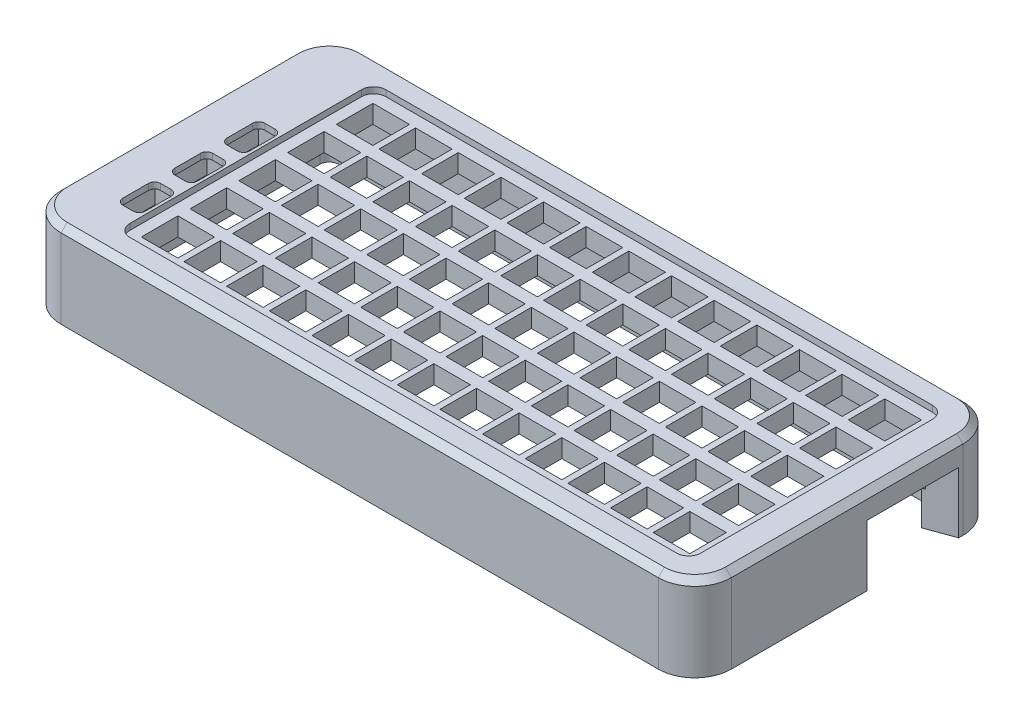
from build123d import *

# Parameters (mm, degrees)
SKETCH_1_W          = 110
SKETCH_1_H          = 50
EXTRUDE_1_DEPTH     = 3
SKETCH_2_W          = 6
SKETCH_2_H          = 6
CUT_EXTRUDE_1_DEPTH = 10
SKETCH_3_W          = 110
SKETCH_3_H          = 50
SKETCH_3_W_2        = 93.7
SKETCH_3_H_2        = 42
EXTRUDE_2_DEPTH     = 1
FILLET_1_R          = 6
CUT_EXTRUDE_2_DEPTH = 6
SKETCH_5_W          = 4.5
SKETCH_5_H          = 7
CUT_EXTRUDE_3_DEPTH = 3
FILLET_2_R          = 2
CHAMFER_1_SIZE      = 1
EXTRUDE_3_DEPTH     = 10
CUT_EXTRUDE_4_DEPTH = 7
CUT_EXTRUDE_5_DEPTH = 3.5
SKETCH_10_W         = 12.104271825
SKETCH_10_H         = 2.912306003
CUT_EXTRUDE_6_DEPTH = 6.5
CHAMFER_2_SIZE      = 4
CHAMFER_2_SIZE2     = 1.455880937
CHAMFER_4_SIZE      = 4
CHAMFER_4_SIZE2     = 1.455880937
CHAMFER_5_SIZE      = 4
CHAMFER_5_SIZE2     = 1.455880937
SKETCH_11_R         = 1.55
CUT_EXTRUDE_7_DEPTH = 2
CUT_EXTRUDE_8_DEPTH = 10


with BuildPart() as part:
    # 草图1 → 凸台-拉伸1 (new body)
    with BuildSketch(Plane(origin=(0, 0, 0), x_dir=(1, 0, 0), z_dir=(0, 1, 0))):
        Rectangle(SKETCH_1_W, SKETCH_1_H)
    extrude(amount=EXTRUDE_1_DEPTH)

    # 草图2 → 切除-拉伸1 (cut)
    with BuildSketch(Plane.XZ):
        with Locations((45.1750889, 8.00003429)):
            Rectangle(SKETCH_2_W, SKETCH_2_H)
        with Locations((45.1750889, 16.00003429)):
            Rectangle(SKETCH_2_W, SKETCH_2_H)
        with Locations((45.1750889, 3.429e-05)):
            Rectangle(SKETCH_2_W, SKETCH_2_H)
        with Locations((45.1750889, -7.99996571)):
            Rectangle(SKETCH_2_W, SKETCH_2_H)
        with Locations((45.1750889, -15.99996571)):
            Rectangle(SKETCH_2_W, SKETCH_2_H)
        with Locations((38.1750889, 8.00003429)):
            Rectangle(SKETCH_2_W, SKETCH_2_H)
        with Locations((38.1750889, 3.429e-05)):
            Rectangle(SKETCH_2_W, SKETCH_2_H)
        with Locations((38.1750889, -7.99996571)):
            Rectangle(SKETCH_2_W, SKETCH_2_H)
        with Locations((38.1750889, -15.99996571)):
            Rectangle(SKETCH_2_W, SKETCH_2_H)
        with Locations((31.1750889, 8.00003429)):
            Rectangle(SKETCH_2_W, SKETCH_2_H)
        with Locations((31.1750889, 3.429e-05)):
            Rectangle(SKETCH_2_W, SKETCH_2_H)
        with Locations((31.1750889, -7.99996571)):
            Rectangle(SKETCH_2_W, SKETCH_2_H)
        with Locations((31.1750889, -15.99996571)):
            Rectangle(SKETCH_2_W, SKETCH_2_H)
        with Locations((24.1750889, 8.00003429)):
            Rectangle(SKETCH_2_W, SKETCH_2_H)
        with Locations((24.1750889, 3.429e-05)):
            Rectangle(SKETCH_2_W, SKETCH_2_H)
        with Locations((24.1750889, -7.99996571)):
            Rectangle(SKETCH_2_W, SKETCH_2_H)
        with Locations((24.1750889, -15.99996571)):
            Rectangle(SKETCH_2_W, SKETCH_2_H)
        with Locations((17.1750889, 8.00003429)):
            Rectangle(SKETCH_2_W, SKETCH_2_H)
        with Locations((17.1750889, 3.429e-05)):
            Rectangle(SKETCH_2_W, SKETCH_2_H)
        with Locations((17.1750889, -7.99996571)):
            Rectangle(SKETCH_2_W, SKETCH_2_H)
        with Locations((17.1750889, -15.99996571)):
            Rectangle(SKETCH_2_W, SKETCH_2_H)
        with Locations((10.1750889, 8.00003429)):
            Rectangle(SKETCH_2_W, SKETCH_2_H)
        with Locations((10.1750889, 3.429e-05)):
            Rectangle(SKETCH_2_W, SKETCH_2_H)
        with Locations((10.1750889, -7.99996571)):
            Rectangle(SKETCH_2_W, SKETCH_2_H)
        with Locations((10.1750889, -15.99996571)):
            Rectangle(SKETCH_2_W, SKETCH_2_H)
        with Locations((3.1750889, 8.00003429)):
            Rectangle(SKETCH_2_W, SKETCH_2_H)
        with Locations((3.1750889, 3.429e-05)):
            Rectangle(SKETCH_2_W, SKETCH_2_H)
        with Locations((3.1750889, -7.99996571)):
            Rectangle(SKETCH_2_W, SKETCH_2_H)
        with Locations((3.1750889, -15.99996571)):
            Rectangle(SKETCH_2_W, SKETCH_2_H)
        with Locations((-3.8249111, 8.00003429)):
            Rectangle(SKETCH_2_W, SKETCH_2_H)
        with Locations((-3.8249111, 3.429e-05)):
            Rectangle(SKETCH_2_W, SKETCH_2_H)
        with Locations((-3.8249111, -7.99996571)):
            Rectangle(SKETCH_2_W, SKETCH_2_H)
        with Locations((-3.8249111, -15.99996571)):
            Rectangle(SKETCH_2_W, SKETCH_2_H)
        with Locations((-10.8249111, 8.00003429)):
            Rectangle(SKETCH_2_W, SKETCH_2_H)
        with Locations((-10.8249111, 3.429e-05)):
            Rectangle(SKETCH_2_W, SKETCH_2_H)
        with Locations((-10.8249111, -7.99996571)):
            Rectangle(SKETCH_2_W, SKETCH_2_H)
        with Locations((-10.8249111, -15.99996571)):
            Rectangle(SKETCH_2_W, SKETCH_2_H)
        with Locations((-17.8249111, 8.00003429)):
            Rectangle(SKETCH_2_W, SKETCH_2_H)
        with Locations((-17.8249111, 3.429e-05)):
            Rectangle(SKETCH_2_W, SKETCH_2_H)
        with Locations((-17.8249111, -7.99996571)):
            Rectangle(SKETCH_2_W, SKETCH_2_H)
        with Locations((-17.8249111, -15.99996571)):
            Rectangle(SKETCH_2_W, SKETCH_2_H)
        with Locations((-24.8249111, 8.00003429)):
            Rectangle(SKETCH_2_W, SKETCH_2_H)
        with Locations((-24.8249111, 3.429e-05)):
            Rectangle(SKETCH_2_W, SKETCH_2_H)
        with Locations((-24.8249111, -7.99996571)):
            Rectangle(SKETCH_2_W, SKETCH_2_H)
        with Locations((-24.8249111, -15.99996571)):
            Rectangle(SKETCH_2_W, SKETCH_2_H)
        with Locations((-31.8249111, 8.00003429)):
            Rectangle(SKETCH_2_W, SKETCH_2_H)
        with Locations((-31.8249111, 3.429e-05)):
            Rectangle(SKETCH_2_W, SKETCH_2_H)
        with Locations((-31.8249111, -7.99996571)):
            Rectangle(SKETCH_2_W, SKETCH_2_H)
        with Locations((-31.8249111, -15.99996571)):
            Rectangle(SKETCH_2_W, SKETCH_2_H)
        with Locations((-38.8249111, 8.00003429)):
            Rectangle(SKETCH_2_W, SKETCH_2_H)
        with Locations((-38.8249111, 3.429e-05)):
            Rectangle(SKETCH_2_W, SKETCH_2_H)
        with Locations((-38.8249111, -7.99996571)):
            Rectangle(SKETCH_2_W, SKETCH_2_H)
        with Locations((-38.8249111, -15.99996571)):
            Rectangle(SKETCH_2_W, SKETCH_2_H)
        with Locations((38.1750889, 16.00003429)):
            Rectangle(SKETCH_2_W, SKETCH_2_H)
        with Locations((31.1750889, 16.00003429)):
            Rectangle(SKETCH_2_W, SKETCH_2_H)
        with Locations((24.1750889, 16.00003429)):
            Rectangle(SKETCH_2_W, SKETCH_2_H)
        with Locations((17.1750889, 16.00003429)):
            Rectangle(SKETCH_2_W, SKETCH_2_H)
        with Locations((10.1750889, 16.00003429)):
            Rectangle(SKETCH_2_W, SKETCH_2_H)
        with Locations((3.1750889, 16.00003429)):
            Rectangle(SKETCH_2_W, SKETCH_2_H)
        with Locations((-3.8249111, 16.00003429)):
            Rectangle(SKETCH_2_W, SKETCH_2_H)
        with Locations((-10.8249111, 16.00003429)):
            Rectangle(SKETCH_2_W, SKETCH_2_H)
        with Locations((-17.8249111, 16.00003429)):
            Rectangle(SKETCH_2_W, SKETCH_2_H)
        with Locations((-24.8249111, 16.00003429)):
            Rectangle(SKETCH_2_W, SKETCH_2_H)
        with Locations((-31.8249111, 16.00003429)):
            Rectangle(SKETCH_2_W, SKETCH_2_H)
        with Locations((-38.8249111, 16.00003429)):
            Rectangle(SKETCH_2_W, SKETCH_2_H)
    extrude(amount=-CUT_EXTRUDE_1_DEPTH, mode=Mode.SUBTRACT)

    # 草图3 → 凸台-拉伸2 (add)
    with BuildSketch(Plane(origin=(0, 3, 0), x_dir=(1, 0, 0), z_dir=(0, 1, 0))):
        Rectangle(SKETCH_3_W, SKETCH_3_H)
        with Locations((3.15, 0)):
            Rectangle(SKETCH_3_W_2, SKETCH_3_H_2, mode=Mode.SUBTRACT)
    extrude(amount=EXTRUDE_2_DEPTH)

    # 圆角1
    fillet_1_edges = [part.edges().sort_by_distance(p)[0] for p in [
        (55, 2, 25),
        (-55, 2, 25),
        (-55, 2, -25),
        (55, 2, -25),
    ]]
    fillet(fillet_1_edges, radius=FILLET_1_R)

    # 草图4 → 切除-拉伸2 (cut)
    with BuildSketch(Plane.XZ):
        with BuildLine():
            Line((-45.161201687, -0.10000635), (-46.861201687, -0.10000635))
            ThreePointArc((-46.861201687, -0.10000635), (-47.568308468, -0.392899569), (-47.861201687, -1.10000635))
            Line((-47.861201687, -1.10000635), (-47.861201687, -5.30000635))
            ThreePointArc((-47.861201687, -5.30000635), (-47.568308468, -6.007113131), (-46.861201687, -6.30000635))
            Line((-46.861201687, -6.30000635), (-45.161201687, -6.30000635))
            ThreePointArc((-45.161201687, -6.30000635), (-44.454094906, -6.007113131), (-44.161201687, -5.30000635))
            Line((-44.161201687, -5.30000635), (-44.161201687, -1.10000635))
            ThreePointArc((-44.161201687, -1.10000635), (-44.454094906, -0.392899569), (-45.161201687, -0.10000635))
        make_face()
        with BuildLine():
            Line((-44.161201687, 7.44999365), (-44.161201687, 3.24999365))
            ThreePointArc((-44.161201687, 3.24999365), (-44.454094906, 2.542886869), (-45.161201687, 2.24999365))
            Line((-45.161201687, 2.24999365), (-46.861201687, 2.24999365))
            ThreePointArc((-46.861201687, 2.24999365), (-47.568308468, 2.542886869), (-47.861201687, 3.24999365))
            Line((-47.861201687, 3.24999365), (-47.861201687, 7.44999365))
            ThreePointArc((-47.861201687, 7.44999365), (-47.568308468, 8.157100431), (-46.861201687, 8.44999365))
            Line((-46.861201687, 8.44999365), (-45.161201687, 8.44999365))
            ThreePointArc((-45.161201687, 8.44999365), (-44.454094906, 8.157100431), (-44.161201687, 7.44999365))
        make_face()
        with BuildLine():
            Line((-44.161201687, 15.99999365), (-44.161201687, 11.79999365))
            ThreePointArc((-44.161201687, 11.79999365), (-44.454094906, 11.092886869), (-45.161201687, 10.79999365))
            Line((-45.161201687, 10.79999365), (-46.861201687, 10.79999365))
            ThreePointArc((-46.861201687, 10.79999365), (-47.568308468, 11.092886869), (-47.861201687, 11.79999365))
            Line((-47.861201687, 11.79999365), (-47.861201687, 15.99999365))
            ThreePointArc((-47.861201687, 15.99999365), (-47.568308468, 16.707100431), (-46.861201687, 16.99999365))
            Line((-46.861201687, 16.99999365), (-45.161201687, 16.99999365))
            ThreePointArc((-45.161201687, 16.99999365), (-44.454094906, 16.707100431), (-44.161201687, 15.99999365))
        make_face()
    extrude(amount=-CUT_EXTRUDE_2_DEPTH, mode=Mode.SUBTRACT)

    # 草图5 → 切除-拉伸3 (cut)
    with BuildSketch(Plane.XZ):
        with Locations((-46.011201687, 5.29999365)):
            Rectangle(SKETCH_5_W, SKETCH_5_H)
        with Locations((-46.011201687, -3.20000635)):
            Rectangle(SKETCH_5_W, SKETCH_5_H)
        with Locations((-46.011201687, 13.79999365)):
            Rectangle(SKETCH_5_W, SKETCH_5_H)
    extrude(amount=-CUT_EXTRUDE_3_DEPTH, mode=Mode.SUBTRACT)

    # 圆角2
    fillet_2_edges = [part.edges().sort_by_distance(p)[0] for p in [
        (-43.7, 3.5, 21),
        (50, 3.5, 21),
        (50, 3.5, -21),
        (-43.7, 3.5, -21),
    ]]
    fillet(fillet_2_edges, radius=FILLET_2_R)

    # 倒角1
    chamfer_1_edges = [part.edges().sort_by_distance(p)[0] for p in [
        (-55, 4, 0),
        (0, 4, -25),
        (0, 4, 25),
        (55, 4, 0),
        (53.242640687, 4, -23.242640687),
        (53.242640687, 4, 23.242640687),
        (-53.242640687, 4, 23.242640687),
        (-53.242640687, 4, -23.242640687),
    ]]
    chamfer(chamfer_1_edges, length=CHAMFER_1_SIZE)

    # 草图6 → 凸台-拉伸3 (add)
    with BuildSketch(Plane.XZ):
        with BuildLine():
            Line((-55, 19), (-55, -19))
            ThreePointArc((-55, -19), (-53.242640687, -23.242640687), (-49, -25))
            Line((-49, -25), (49, -25))
            ThreePointArc((49, -25), (53.242640687, -23.242640687), (55, -19))
            Line((55, -19), (55, 19))
            ThreePointArc((55, 19), (53.242640687, 23.242640687), (49, 25))
            Line((49, 25), (-49, 25))
            ThreePointArc((-49, 25), (-53.242640687, 23.242640687), (-55, 19))
        make_face()
        with BuildLine():
            Line((50.5, 19), (50.5, -19))
            ThreePointArc((50.5, -19), (50.060660172, -20.060660172), (49, -20.5))
            Line((49, -20.5), (-49, -20.5))
            ThreePointArc((-49, -20.5), (-50.060660172, -20.060660172), (-50.5, -19))
            Line((-50.5, -19), (-50.5, 19))
            ThreePointArc((-50.5, 19), (-50.060660172, 20.060660172), (-49, 20.5))
            Line((-49, 20.5), (49, 20.5))
            ThreePointArc((49, 20.5), (50.060660172, 20.060660172), (50.5, 19))
        make_face(mode=Mode.SUBTRACT)
    extrude(amount=EXTRUDE_3_DEPTH)

    # 草图8 → 切除-拉伸4 (cut)
    with BuildSketch(Plane(origin=(-50.5, 0, 0), x_dir=(0, 0, -1), z_dir=(1, 0, 0))):
        with BuildLine():
            Line((14.684129805, -5.548450834), (8.683914391, -5.548450834))
            ThreePointArc((8.683914391, -5.548450834), (6.935463557, -3.8), (8.683914391, -2.051549166))
            Line((8.683914391, -2.051549166), (14.684129805, -2.051549166))
            ThreePointArc((14.684129805, -2.051549166), (16.432580639, -3.8), (14.684129805, -5.548450834))
        make_face()
    extrude(amount=-CUT_EXTRUDE_4_DEPTH, mode=Mode.SUBTRACT)

    # 草图9 → 切除-拉伸5 (cut)
    with BuildSketch(Plane.ZY.offset(55)):
        with BuildLine():
            Line((-15.088320827, -0.03005075), (-8.153052575, -0.03005075))
            ThreePointArc((-8.153052575, -0.03005075), (-4.325593117, -3.857510207), (-8.153052575, -7.684969665))
            Line((-8.153052575, -7.684969665), (-15.088320827, -7.684969665))
            ThreePointArc((-15.088320827, -7.684969665), (-18.915780285, -3.857510207), (-15.088320827, -0.03005075))
        make_face()
    extrude(amount=-CUT_EXTRUDE_5_DEPTH, mode=Mode.SUBTRACT)

    # 草图10 → 切除-拉伸6 (cut)
    with BuildSketch(Plane.ZY.offset(-50.5)):
        with Locations((-10.796340626, -2.900297793)):
            Rectangle(SKETCH_10_W, SKETCH_10_H)
    extrude(amount=-CUT_EXTRUDE_6_DEPTH, mode=Mode.SUBTRACT)

    # 倒角2
    chamfer_2_edges = [part.edges().sort_by_distance(p)[0] for p in [
        (55, -1.444144791, -10.796340625),
    ]]
    chamfer_2_side = [part.faces().sort_by_distance(p)[0] for p in [
        (52.75, -1.444144791, -10.796340625),
    ]]
    chamfer(chamfer_2_edges, length=CHAMFER_2_SIZE, length2=CHAMFER_2_SIZE2, reference=chamfer_2_side[0])

    # 倒角4
    chamfer_4_edges = [part.edges().sort_by_distance(p)[0] for p in [
        (55, -2.900297793, -4.744204713),
    ]]
    chamfer_4_side = [part.faces().sort_by_distance(p)[0] for p in [
        (52.916641188, -2.547361456, -4.744204713),
    ]]
    chamfer(chamfer_4_edges, length=CHAMFER_4_SIZE, length2=CHAMFER_4_SIZE2, reference=chamfer_4_side[0])

    # 倒角5
    chamfer_5_edges = [part.edges().sort_by_distance(p)[0] for p in [
        (55, -2.900297793, -16.848476538),
    ]]
    chamfer_5_side = [part.faces().sort_by_distance(p)[0] for p in [
        (52.916641188, -2.547361456, -16.848476538),
    ]]
    chamfer(chamfer_5_edges, length=CHAMFER_5_SIZE, length2=CHAMFER_5_SIZE2, reference=chamfer_5_side[0])

    # 草图11 → 切除-拉伸7 (cut)
    with BuildSketch(Plane.XZ.offset(10)):
        with Locations((0, -22.7)):
            Circle(SKETCH_11_R)
        with Locations((20, -22.7)):
            Circle(SKETCH_11_R)
        with Locations((40, -22.7)):
            Circle(SKETCH_11_R)
        with Locations((-20, -22.7)):
            Circle(SKETCH_11_R)
        with Locations((-40, -22.7)):
            Circle(SKETCH_11_R)
        with Locations((-40, 22.7)):
            Circle(SKETCH_11_R)
        with Locations((-20, 22.7)):
            Circle(SKETCH_11_R)
        with Locations((40, 22.7)):
            Circle(SKETCH_11_R)
        with Locations((20, 22.7)):
            Circle(SKETCH_11_R)
        with Locations((0, 22.7)):
            Circle(SKETCH_11_R)
    extrude(amount=-CUT_EXTRUDE_7_DEPTH, mode=Mode.SUBTRACT)

    # 草图14 → 切除-拉伸8 (cut)
    with BuildSketch(Plane(origin=(0, -4.356450794, 0), x_dir=(1, 0, 0), z_dir=(0, 1, 0))):
        Polygon((55, 18.304357475), (55, 3.288323776), (53.809787947, 3.721525535), (49.176659409, 5.407846415), (49.176659409, 16.184834836), (53.809787947, 17.871155715), align=None)
    extrude(amount=-CUT_EXTRUDE_8_DEPTH, mode=Mode.SUBTRACT)


solid = part.part
